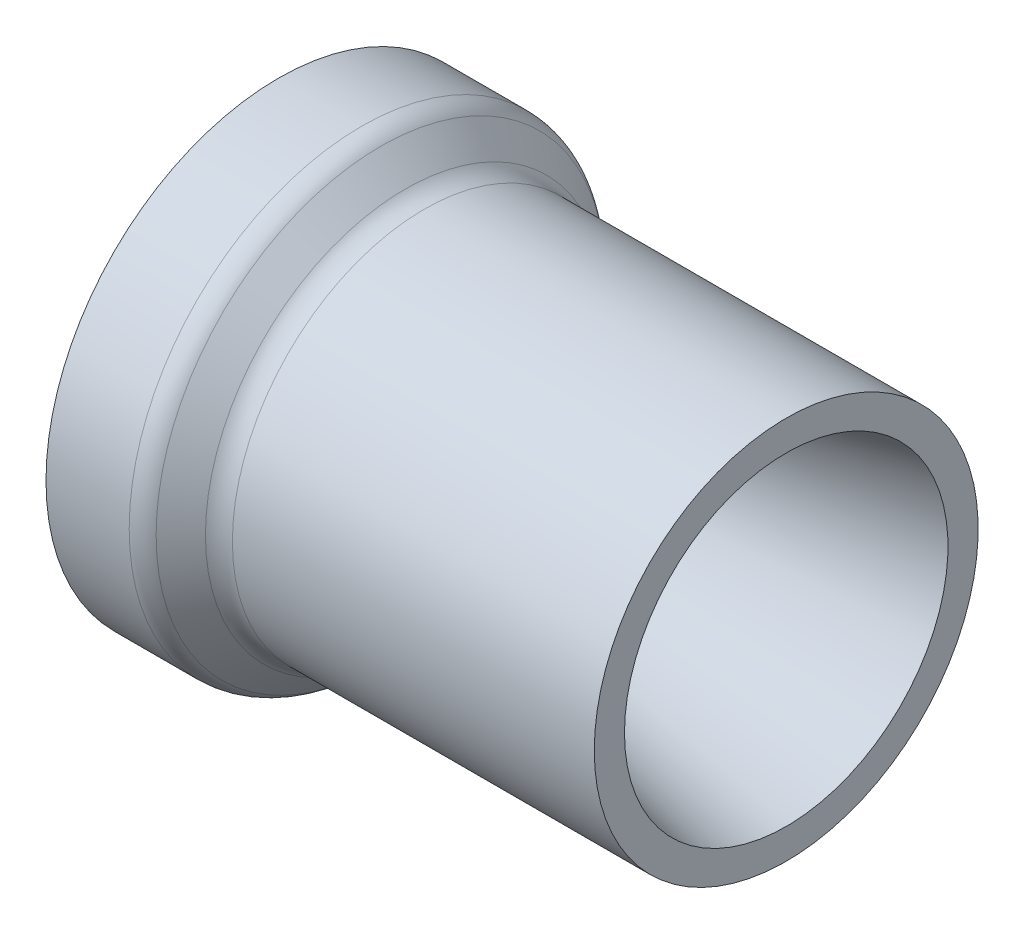
from build123d import *


with BuildPart() as part:
    # Sketch1 → Revolve1 (revolve)
    with BuildSketch(Plane.XY):
        with BuildLine():
            Line((0, 0.2921), (19.594743879, 0.2921))
            ThreePointArc((19.594743879, 0.2921), (22.024783674, 0.775464969), (24.084871939, 2.151971939))
            Line((24.084871939, 2.151971939), (29.890128061, 7.957228061))
            ThreePointArc((29.890128061, 7.957228061), (31.950216326, 9.333735031), (34.380256121, 9.8171))
            Line((34.380256121, 9.8171), (119.619043514, 9.8171))
            Line((119.619043514, 9.8171), (119.619043514, 16.9291))
            Line((119.619043514, 16.9291), (24.020959689, 37.2491))
            Line((24.020959689, 37.2491), (17.670959689, 37.2491))
            Line((17.670959689, 37.2491), (0, 6.6421))
            Line((0, 6.6421), (0, 0.2921))
        make_face()
    revolve(axis=Axis((0, 55.0291, 0), (1, 0, 0)))


solid = part.part
